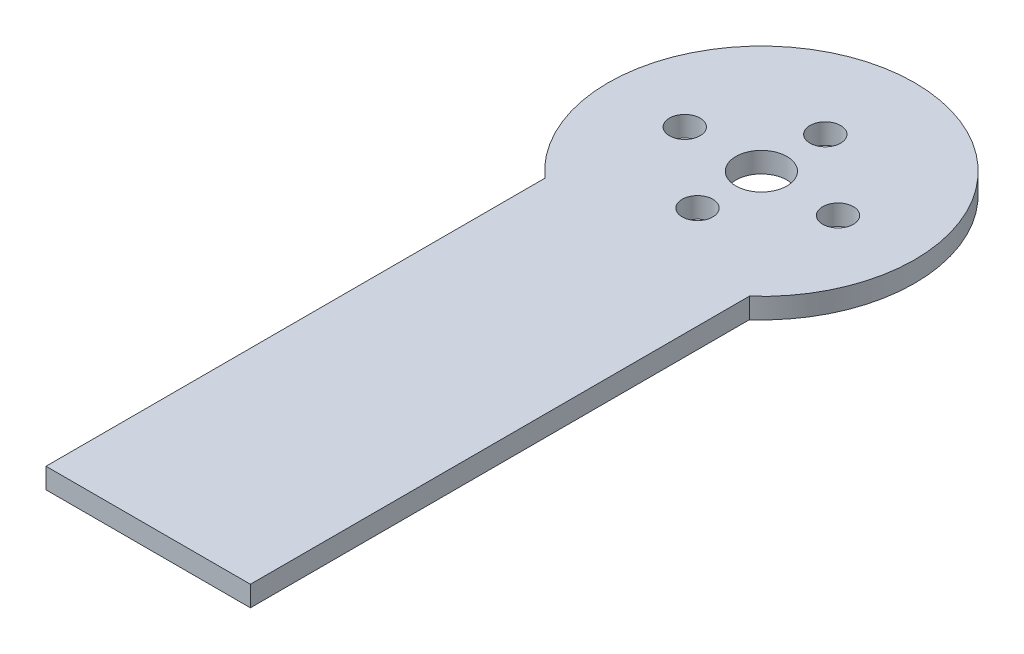
from build123d import *

# Parameters (mm, degrees)
SKETCH1_R           = 1.905
SKETCH1_R_2         = 3.175
BOSS_EXTRUDE1_DEPTH = 2.54


with BuildPart() as part:
    # Sketch1 → Boss-Extrude1 (new body)
    with BuildSketch(Plane(origin=(0, 0, 0), x_dir=(1, 0, 0), z_dir=(0, 1, 0))):
        with BuildLine():
            Line((12.7, -76.2), (12.7, -14.199031657))
            ThreePointArc((12.7, -14.199031657), (0, 19.05), (-12.7, -14.199031657))
            Line((-12.7, -14.199031657), (-12.7, -76.2))
            Line((-12.7, -76.2), (12.7, -76.2))
        make_face()
        with Locations((9.525, 0)):
            Circle(SKETCH1_R, mode=Mode.SUBTRACT)
        with Locations((-9.525, 0)):
            Circle(SKETCH1_R, mode=Mode.SUBTRACT)
        with Locations((0, 7.9375)):
            Circle(SKETCH1_R, mode=Mode.SUBTRACT)
        with Locations((0, -7.9375)):
            Circle(SKETCH1_R, mode=Mode.SUBTRACT)
        Circle(SKETCH1_R_2, mode=Mode.SUBTRACT)
    extrude(amount=BOSS_EXTRUDE1_DEPTH)


solid = part.part
